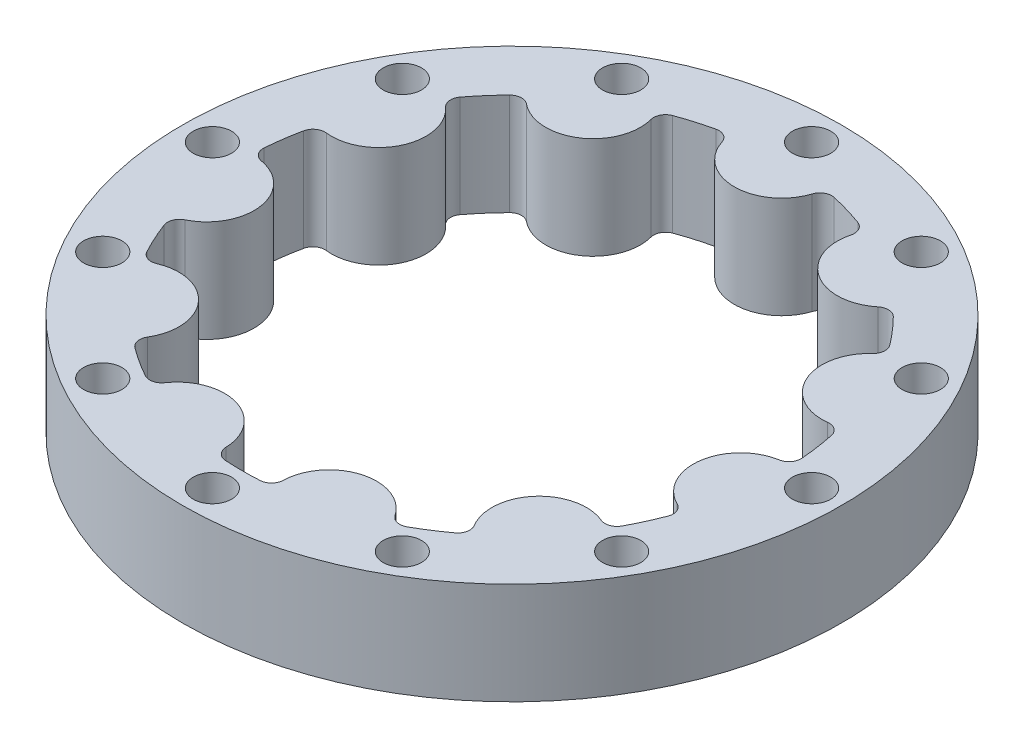
from build123d import *

# Parameters (mm, degrees)
SKETCH1_R           = 27.5
BOSS_EXTRUDE2_DEPTH = 8.5
FILLET2_R           = 1
SKETCH2_R           = 1.6
CUT_EXTRUDE1_DEPTH  = 10


with BuildPart() as part:
    # Sketch1 → Boss-Extrude2 (new body)
    with BuildSketch(Plane(origin=(0, 0, 0), x_dir=(1, 0, 0), z_dir=(0, 1, 0))):
        Circle(SKETCH1_R)
        with BuildLine():
            ThreePointArc((22.487763135, 0.741963062), (18.361187747, -2.63994025), (21.36781557, -7.04744335))
            ThreePointArc((21.36781557, -7.04744335), (20.466719895, -9.346837793), (19.319045699, -11.533623597))
            ThreePointArc((19.319045699, -11.533623597), (14.019154604, -12.147666615), (14.165614803, -17.480999893))
            ThreePointArc((14.165614803, -17.480999893), (12.164418393, -18.928204489), (10.016667756, -20.147366257))
            ThreePointArc((10.016667756, -20.147366257), (5.226138929, -17.798594661), (2.465931426, -22.364462484))
            ThreePointArc((2.465931426, -22.364462484), (0, -22.5), (-2.465931426, -22.364462484))
            ThreePointArc((-2.465931426, -22.364462484), (-5.226138929, -17.798594661), (-10.016667756, -20.147366257))
            ThreePointArc((-10.016667756, -20.147366257), (-12.164418393, -18.928204489), (-14.165614803, -17.480999893))
            ThreePointArc((-14.165614803, -17.480999893), (-14.019154604, -12.147666615), (-19.319045699, -11.533623597))
            ThreePointArc((-19.319045699, -11.533623597), (-20.466719895, -9.346837793), (-21.36781557, -7.04744335))
            ThreePointArc((-21.36781557, -7.04744335), (-18.361187747, -2.63994025), (-22.487763135, 0.741963062))
            ThreePointArc((-22.487763135, 0.741963062), (-22.270982442, 3.202083861), (-21.785885871, 5.623626661))
            ThreePointArc((-21.785885871, 5.623626661), (-16.873673514, 7.705948491), (-18.516774666, 12.781981691))
            ThreePointArc((-18.516774666, 12.781981691), (-17.004365423, 14.734366514), (-15.28709134, 16.509234942))
            ThreePointArc((-15.28709134, 16.509234942), (-10.028887164, 15.605253034), (-8.666841075, 20.763811447))
            ThreePointArc((-8.666841075, 20.763811447), (-6.338982529, 21.588591906), (-3.934753321, 22.153277778))
            ThreePointArc((-3.934753321, 22.153277778), (0, 18.55), (3.934753321, 22.153277778))
            ThreePointArc((3.934753321, 22.153277778), (6.338982529, 21.588591906), (8.666841075, 20.763811447))
            ThreePointArc((8.666841075, 20.763811447), (10.028887164, 15.605253034), (15.28709134, 16.509234942))
            ThreePointArc((15.28709134, 16.509234942), (17.004365423, 14.734366514), (18.516774666, 12.781981691))
            ThreePointArc((18.516774666, 12.781981691), (16.873673514, 7.705948491), (21.785885871, 5.623626661))
            ThreePointArc((21.785885871, 5.623626661), (22.270982442, 3.202083861), (22.487763135, 0.741963062))
        make_face(mode=Mode.SUBTRACT)
    extrude(amount=BOSS_EXTRUDE2_DEPTH)

    # Fillet2
    fillet2_edges = [part.edges().sort_by_distance(p)[0] for p in [
        (-18.516774666, 4.25, -12.781981691),
        (-21.785885871, 4.25, -5.623626661),
        (-22.487763135, 4.25, -0.741963062),
        (-21.36781557, 4.25, 7.04744335),
        (-19.319045699, 4.25, 11.533623597),
        (-14.165614803, 4.25, 17.480999893),
        (-10.016667756, 4.25, 20.147366257),
        (-2.465931426, 4.25, 22.364462484),
        (2.465931426, 4.25, 22.364462484),
        (10.016667756, 4.25, 20.147366257),
        (14.165614803, 4.25, 17.480999893),
        (19.319045699, 4.25, 11.533623597),
        (21.36781557, 4.25, 7.04744335),
        (22.487763135, 4.25, -0.741963062),
        (21.785885871, 4.25, -5.623626661),
        (18.516774666, 4.25, -12.781981691),
        (15.28709134, 4.25, -16.509234942),
        (8.666841075, 4.25, -20.763811447),
        (3.934753321, 4.25, -22.153277778),
        (-3.934753321, 4.25, -22.153277778),
        (-8.666841075, 4.25, -20.763811447),
        (-15.28709134, 4.25, -16.509234942),
    ]]
    fillet(fillet2_edges, radius=FILLET2_R)

    # Sketch2 → Cut-Extrude1 (cut)
    with BuildSketch(Plane.XZ):
        with Locations((25, 0)):
            Circle(SKETCH2_R)
        with Locations((21.650635095, -12.5)):
            Circle(SKETCH2_R)
        with Locations((12.5, -21.650635095)):
            Circle(SKETCH2_R)
        with Locations((0, -25)):
            Circle(SKETCH2_R)
        with Locations((-12.5, -21.650635095)):
            Circle(SKETCH2_R)
        with Locations((-21.650635095, -12.5)):
            Circle(SKETCH2_R)
        with Locations((-25, 0)):
            Circle(SKETCH2_R)
        with Locations((-21.650635095, 12.5)):
            Circle(SKETCH2_R)
        with Locations((-12.5, 21.650635095)):
            Circle(SKETCH2_R)
        with Locations((0, 25)):
            Circle(SKETCH2_R)
        with Locations((12.5, 21.650635095)):
            Circle(SKETCH2_R)
        with Locations((21.650635095, 12.5)):
            Circle(SKETCH2_R)
    extrude(amount=-CUT_EXTRUDE1_DEPTH, mode=Mode.SUBTRACT)


solid = part.part
